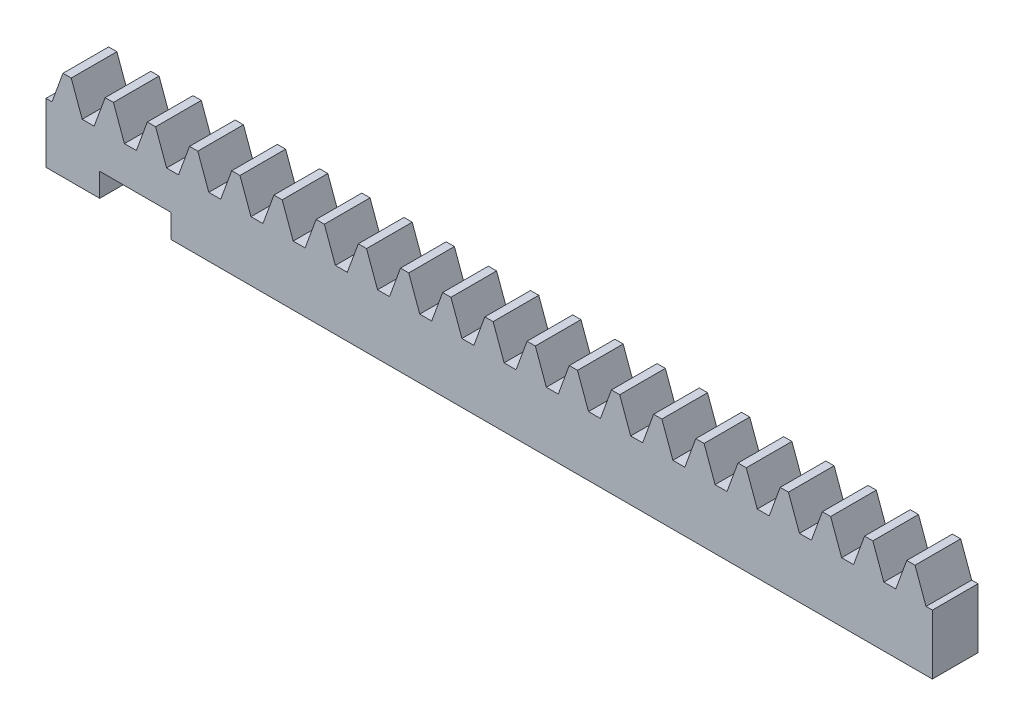
from build123d import *

# Parameters (mm, degrees)
BLANKSKE_W        = 66
BLANKSKE_H        = 6.7
BLANK_DEPTH       = 3.4
TOOTHCUTSIM_DEPTH = 67.426274922
TEETHCUTS_COUNT   = 22
TEETHCUTS_PITCH   = 3.14159265
NOTCH_SKETCH_W    = 5.3
NOTCH_SKETCH_H    = 1.75
NOTCH_DEPTH       = 67.426274922


with BuildPart() as part:
    # BlankSke → Blank (new body)
    with BuildSketch(Plane.XY):
        with Locations((33, 3.35)):
            Rectangle(BLANKSKE_W, BLANKSKE_H)
    extrude(amount=-BLANK_DEPTH)

    # TooCutSkeSim → ToothCutSim (cut, through all)
    with BuildSketch(Plane.XY):
        Polygon((0.44443537, 4.45), (-0.44443537, 4.45), (-1.272613241, 6.7254), (1.272613241, 6.7254), align=None)
    toothcutsim = extrude(amount=-TOOTHCUTSIM_DEPTH, mode=Mode.SUBTRACT)

    # TeethCuts: ToothCutSim ×22
    with Locations(*[(i * TEETHCUTS_PITCH, 0, 0) for i in range(1, TEETHCUTS_COUNT)]):
        add(toothcutsim, mode=Mode.SUBTRACT)

    # notch-sketch → notch (cut, through all)
    with BuildSketch(Plane.XY):
        with Locations((6.65, 0.875)):
            Rectangle(NOTCH_SKETCH_W, NOTCH_SKETCH_H)
    extrude(amount=-NOTCH_DEPTH, mode=Mode.SUBTRACT)


solid = part.part
